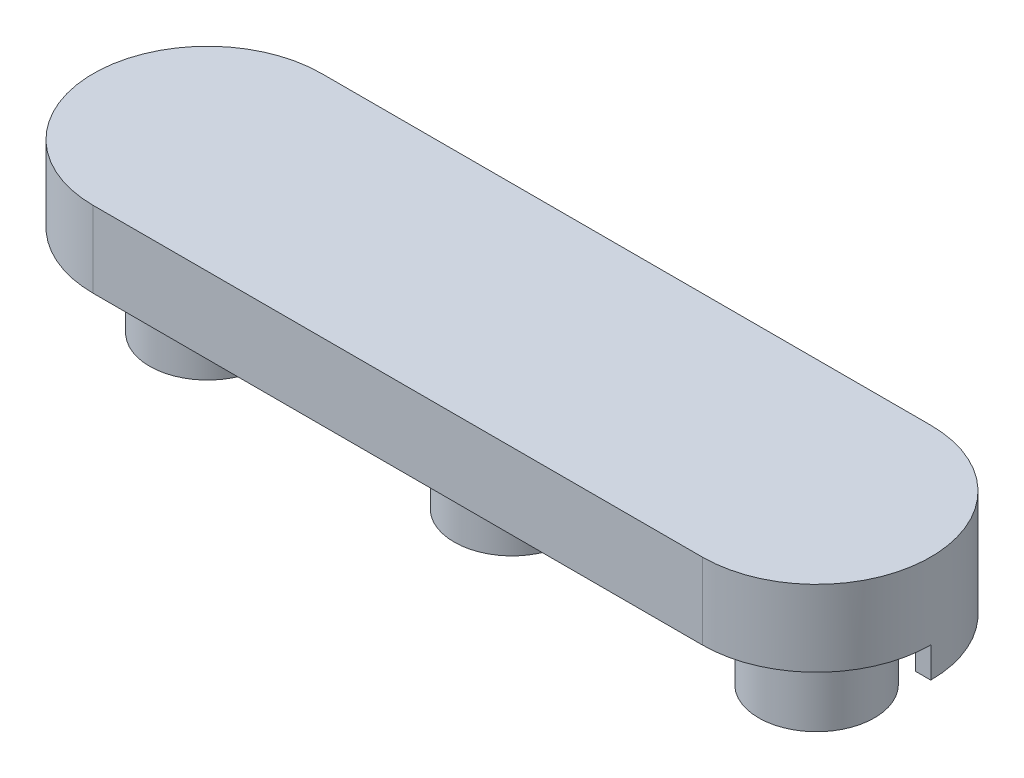
from build123d import *

# Parameters (mm, degrees)
SKETCH1_R        = 2.0955
PLUGS_DEPTH      = 7.62
SKETCH1_R_2      = 4.826
SKETCH1_R_3      = 3.1115
PLUGS_2_DEPTH    = 7.62
PLUGS_3_DEPTH    = 7.62
PLUGS_4_DEPTH    = 7.62
PLUGS_5_DEPTH    = 7.62
PLUGS_6_DEPTH    = 7.62
BACK_PLATE_DEPTH = 6.35
RAIN_GUARD_DEPTH = 2.54


with BuildPart() as part:
    # Sketch1 → Plugs (new body)
    with BuildSketch(Plane(origin=(0, 0, 0), x_dir=(1, 0, 0), z_dir=(0, 1, 0))):
        with Locations((-25.4, 0)):
            Circle(SKETCH1_R)
    extrude(amount=PLUGS_DEPTH)



with BuildPart() as body_2:
    # Sketch1 → Plugs 2 (new body)
    with BuildSketch(Plane(origin=(0, 0, 0), x_dir=(1, 0, 0), z_dir=(0, 1, 0))):
        with Locations((-25.4, 0)):
            Circle(SKETCH1_R_2)
        with Locations((-25.4, 0)):
            Circle(SKETCH1_R_3, mode=Mode.SUBTRACT)
    extrude(amount=PLUGS_2_DEPTH)


with BuildPart() as body_3:
    # Sketch1 → Plugs 3 (new body)
    with BuildSketch(Plane(origin=(0, 0, 0), x_dir=(1, 0, 0), z_dir=(0, 1, 0))):
        Circle(SKETCH1_R)
    extrude(amount=PLUGS_3_DEPTH)


with BuildPart() as body_4:
    # Sketch1 → Plugs 4 (new body)
    with BuildSketch(Plane(origin=(0, 0, 0), x_dir=(1, 0, 0), z_dir=(0, 1, 0))):
        Circle(SKETCH1_R_2)
        Circle(SKETCH1_R_3, mode=Mode.SUBTRACT)
    extrude(amount=PLUGS_4_DEPTH)


with BuildPart() as body_5:
    # Sketch1 → Plugs 5 (new body)
    with BuildSketch(Plane(origin=(0, 0, 0), x_dir=(1, 0, 0), z_dir=(0, 1, 0))):
        with Locations((25.4, 0)):
            Circle(SKETCH1_R)
    extrude(amount=PLUGS_5_DEPTH)


with BuildPart() as body_6:
    # Sketch1 → Plugs 6 (new body)
    with BuildSketch(Plane(origin=(0, 0, 0), x_dir=(1, 0, 0), z_dir=(0, 1, 0))):
        with Locations((25.4, 0)):
            Circle(SKETCH1_R_2)
        with Locations((25.4, 0)):
            Circle(SKETCH1_R_3, mode=Mode.SUBTRACT)
    extrude(amount=PLUGS_6_DEPTH)


with BuildPart() as part_1:
    add(part.part)

    add(body_2.part)  # Back Plate merges body 2

    add(body_3.part)  # Back Plate merges body 3

    add(body_4.part)  # Back Plate merges body 4

    add(body_5.part)  # Back Plate merges body 5

    add(body_6.part)  # Back Plate merges body 6
    # Sketch2 → Back Plate (add)
    with BuildSketch(Plane(origin=(0, 7.62, 0), x_dir=(1, 0, 0), z_dir=(0, 1, 0))):
        with BuildLine():
            Line((-25.4, 9.525), (25.4, 9.525))
            ThreePointArc((25.4, 9.525), (34.925, 0), (25.4, -9.525))
            Line((25.4, -9.525), (-25.4, -9.525))
            ThreePointArc((-25.4, -9.525), (-34.925, 0), (-25.4, 9.525))
        make_face()
    extrude(amount=BACK_PLATE_DEPTH)

    # Sketch3 → Rain Guard (add)
    with BuildSketch(Plane.XZ.offset(-7.62)):
        with BuildLine():
            Line((25.4, -9.525), (-25.4, -9.525))
            ThreePointArc((-25.4, -9.525), (-32.135192091, -6.735192091), (-34.925, 0))
            Line((-34.925, 0), (-33.655, 0))
            ThreePointArc((-33.655, 0), (-31.237166479, -5.837166479), (-25.4, -8.255))
            Line((-25.4, -8.255), (25.4, -8.255))
            ThreePointArc((25.4, -8.255), (31.237166479, -5.837166479), (33.655, 0))
            Line((33.655, 0), (34.925, 0))
            ThreePointArc((34.925, 0), (32.135192091, -6.735192091), (25.4, -9.525))
        make_face()
    extrude(amount=RAIN_GUARD_DEPTH)


solid = part_1.part
